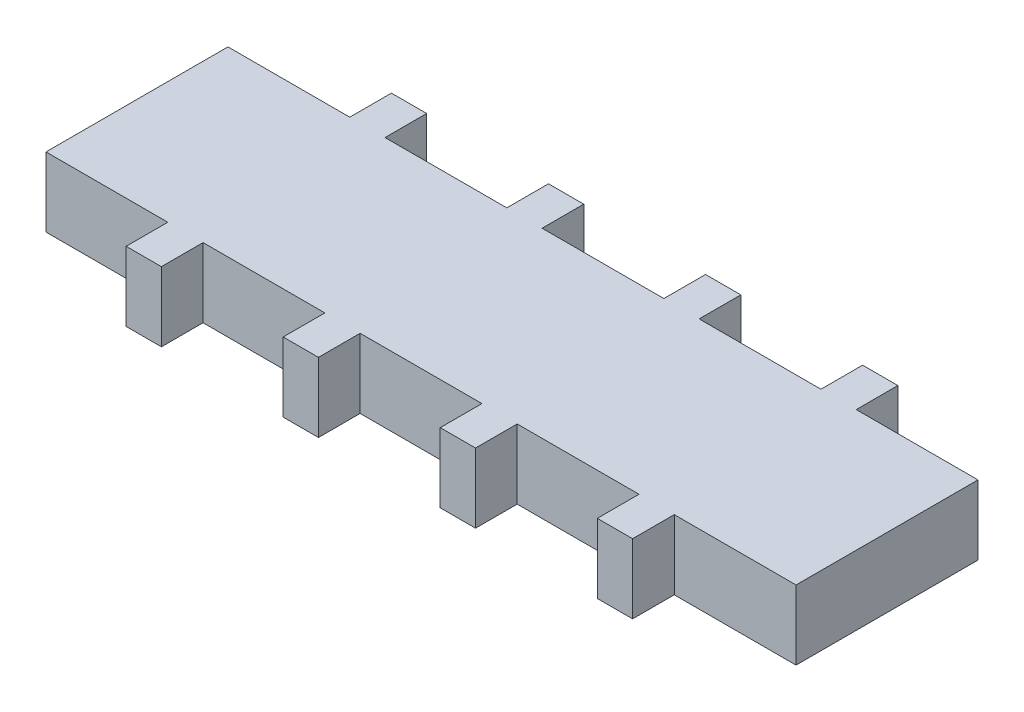
from build123d import *

# Parameters (mm, degrees)
SKETCH1_W           = 54
SKETCH1_H           = 13.1
SKETCH1_W_2         = 2.54
SKETCH1_H_2         = 3
BOSS_EXTRUDE1_DEPTH = 5


with BuildPart() as part:
    # Sketch1 → Boss-Extrude1 (new body)
    with BuildSketch(Plane(origin=(0, 0, 0), x_dir=(1, 0, 0), z_dir=(0, 1, 0))):
        Rectangle(SKETCH1_W, SKETCH1_H)
        with Locations((-16.962, -8.05)):
            Rectangle(SKETCH1_W_2, SKETCH1_H_2)
        with Locations((-5.654, -8.05)):
            Rectangle(SKETCH1_W_2, SKETCH1_H_2)
        with Locations((5.654, -8.05)):
            Rectangle(SKETCH1_W_2, SKETCH1_H_2)
        with Locations((16.962, -8.05)):
            Rectangle(SKETCH1_W_2, SKETCH1_H_2)
        with Locations((16.962, 8.05)):
            Rectangle(SKETCH1_W_2, SKETCH1_H_2)
        with Locations((5.654, 8.05)):
            Rectangle(SKETCH1_W_2, SKETCH1_H_2)
        with Locations((-5.654, 8.05)):
            Rectangle(SKETCH1_W_2, SKETCH1_H_2)
        with Locations((-16.962, 8.05)):
            Rectangle(SKETCH1_W_2, SKETCH1_H_2)
    extrude(amount=BOSS_EXTRUDE1_DEPTH)


solid = part.part
